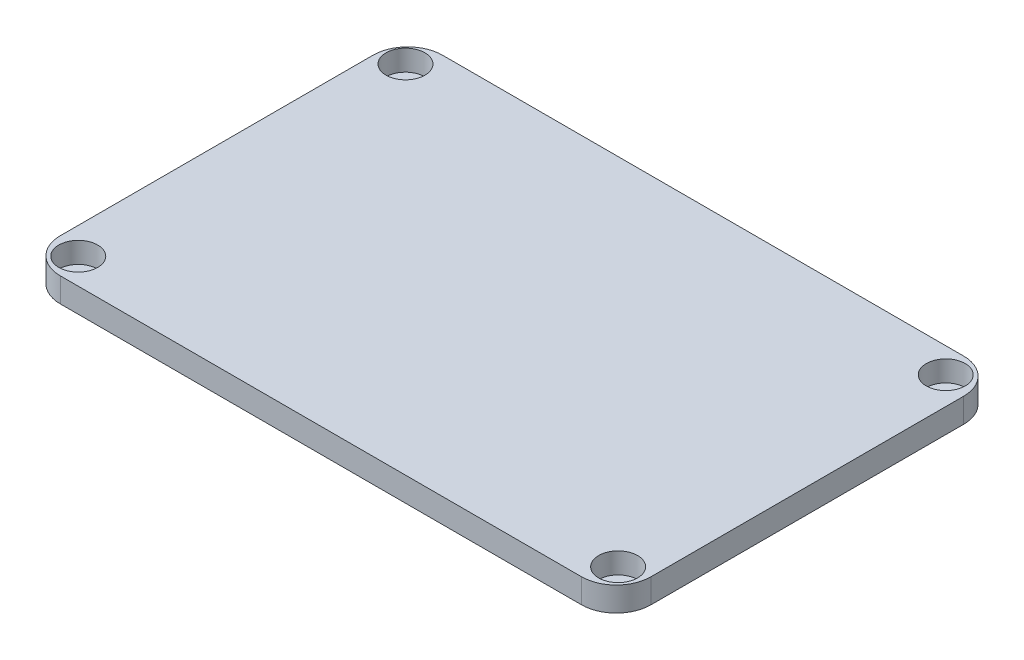
from build123d import *

# Parameters (mm, degrees)
BOSS_EXTRUDE1_DEPTH = 3.5
SKETCH2_R           = 2.8
CUT_EXTRUDE1_DEPTH  = 3


with BuildPart() as part:
    # Sketch1 → Boss-Extrude1 (new body)
    with BuildSketch(Plane(origin=(0, 0, 0), x_dir=(1, 0, 0), z_dir=(0, 1, 0))):
        with BuildLine():
            Line((-20.62248996, 7.565261044), (54.37751004, 7.565261044))
            ThreePointArc((54.37751004, 7.565261044), (57.913043946, 6.10079495), (59.37751004, 2.565261044))
            Line((59.37751004, 2.565261044), (59.37751004, -42.434738956))
            ThreePointArc((59.37751004, -42.434738956), (57.913043946, -45.970272862), (54.37751004, -47.434738956))
            Line((54.37751004, -47.434738956), (-20.62248996, -47.434738956))
            ThreePointArc((-20.62248996, -47.434738956), (-24.158023866, -45.970272862), (-25.62248996, -42.434738956))
            Line((-25.62248996, -42.434738956), (-25.62248996, 2.565261044))
            ThreePointArc((-25.62248996, 2.565261044), (-24.158023866, 6.10079495), (-20.62248996, 7.565261044))
        make_face()
    extrude(amount=BOSS_EXTRUDE1_DEPTH)

    # Sketch2 → Cut-Extrude1 (cut)
    with BuildSketch(Plane(origin=(0, 3.5, 0), x_dir=(1, 0, 0), z_dir=(0, 1, 0))):
        with Locations((-22.187566987, 3.802718615)):
            Circle(SKETCH2_R)
        with Locations((-21.775437199, -43.697281385)):
            Circle(SKETCH2_R)
        with Locations((55.412433013, 3.947865339)):
            Circle(SKETCH2_R)
        with Locations((55.766505812, -43.552134661)):
            Circle(SKETCH2_R)
    extrude(amount=-CUT_EXTRUDE1_DEPTH, mode=Mode.SUBTRACT)


solid = part.part
